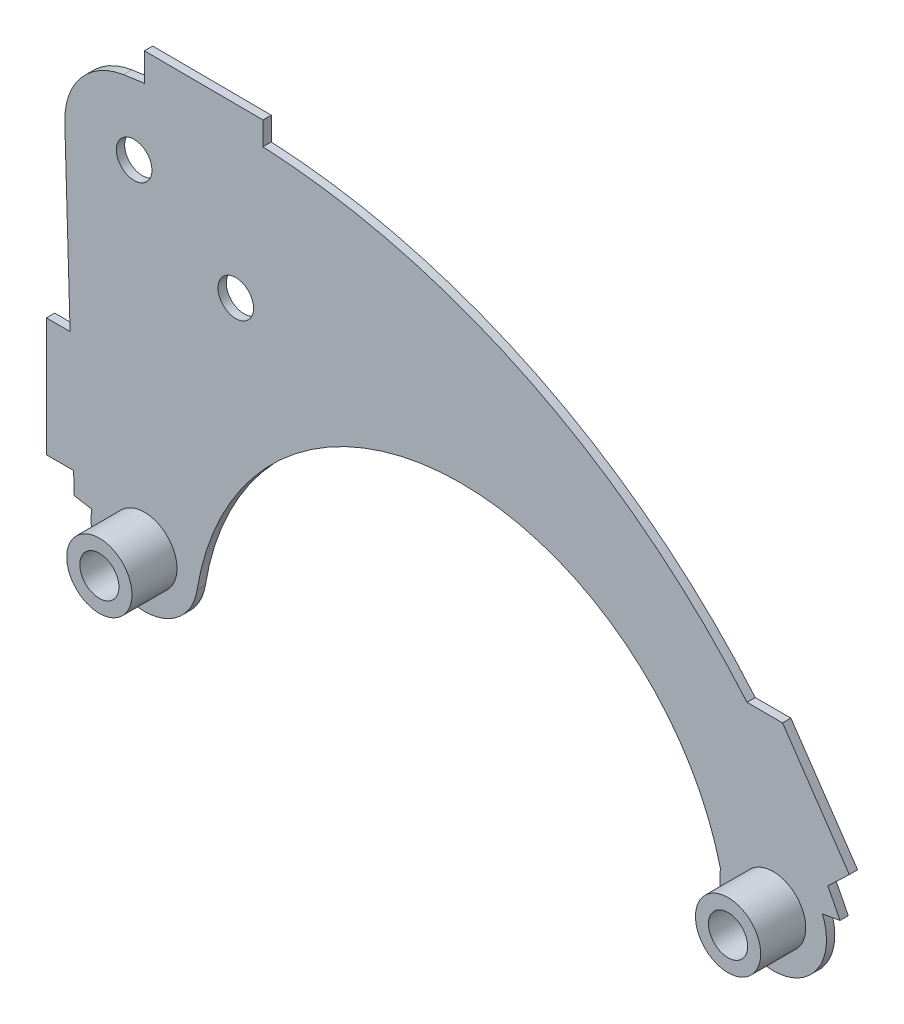
from build123d import *

# Parameters (mm, degrees)
SKETCH1_R           = 16.5
SKETCH1_R_2         = 15
BOSS_EXTRUDE3_DEPTH = 7
SKETCH2_R           = 27.5
SKETCH2_R_2         = 16.5
BOSS_EXTRUDE4_DEPTH = 38
BOSS_EXTRUDE5_DEPTH = 7


with BuildPart() as part:
    # Sketch1 → Boss-Extrude3 (new body)
    with BuildSketch(Plane.XY):
        with BuildLine():
            Line((-322.811275448, 54.020092964), (-308.016991909, 51.544375984))
            ThreePointArc((-308.016991909, 51.544375984), (-297.979605272, 15.041649319), (-263.634141291, -0.882774953))
            Line((-263.634141291, -0.882774953), (-262.985194212, -0.878095462))
            ThreePointArc((-262.985194212, -0.878095462), (-234.213459723, 10.066916736), (-219.209238471, 36.945892575))
            ThreePointArc((-219.209238471, 36.945892575), (-5.54789332, 226.171081865), (222.17000985, 54.119057031))
            ThreePointArc((222.17000985, 54.119057031), (271.744200091, 2.083431527), (308.115870104, 64.070593748))
            Line((308.115870104, 64.070593748), (322.942948353, 66.658271071))
            ThreePointArc((322.942948353, 66.658271071), (72.802770658, 324.018256719), (-281.327086526, 382.296168148))
            ThreePointArc((-281.327086526, 382.296168148), (-317.291599122, 361.87304371), (-330.761322011, 322.769121357))
            Line((-330.761322011, 322.769121357), (-322.811275448, 54.020092964))
        make_face()
        with Locations((-263.634141291, 44.117225047)):
            Circle(SKETCH1_R, mode=Mode.SUBTRACT)
        with Locations((266.5683015, 46.784774614)):
            Circle(SKETCH1_R, mode=Mode.SUBTRACT)
        with Locations((-186.584414745, 266.470160007)):
            Circle(SKETCH1_R_2, mode=Mode.SUBTRACT)
        with Locations((-272.286901184, 324.498892702)):
            Circle(SKETCH1_R_2, mode=Mode.SUBTRACT)
    extrude(amount=BOSS_EXTRUDE3_DEPTH)

    # Sketch2 → Boss-Extrude4 (add)
    with BuildSketch(Plane.XY.offset(7)):
        with Locations((-263.634141291, 44.117225047)):
            Circle(SKETCH2_R)
        with Locations((-263.634141291, 44.117225047)):
            Circle(SKETCH2_R_2, mode=Mode.SUBTRACT)
        with Locations((266.5683015, 46.784774614)):
            Circle(SKETCH2_R)
        with Locations((266.5683015, 46.784774614)):
            Circle(SKETCH2_R_2, mode=Mode.SUBTRACT)
    extrude(amount=BOSS_EXTRUDE4_DEPTH)

    # Sketch3 → Boss-Extrude5 (add)
    with BuildSketch(Plane.XY.offset(7)):
        Polygon((-263.634141291, 408.541652183), (-263.634141291, 384.267252813), (-163.635450853, 388.029879984), (-163.635450853, 408.029879984), align=None)
        Polygon((-326.306060919, 172.160306647), (-346.306060919, 172.160306647), (-346.306060919, 72.160306647), (-323.347893363, 72.160306647), align=None)
        Polygon((244.528320181, 186.784774614), (312.652861422, 86.784774614), (330.829684073, 104.1400142), (274.528320181, 186.784774614), align=None)
    extrude(amount=-BOSS_EXTRUDE5_DEPTH)


solid = part.part
